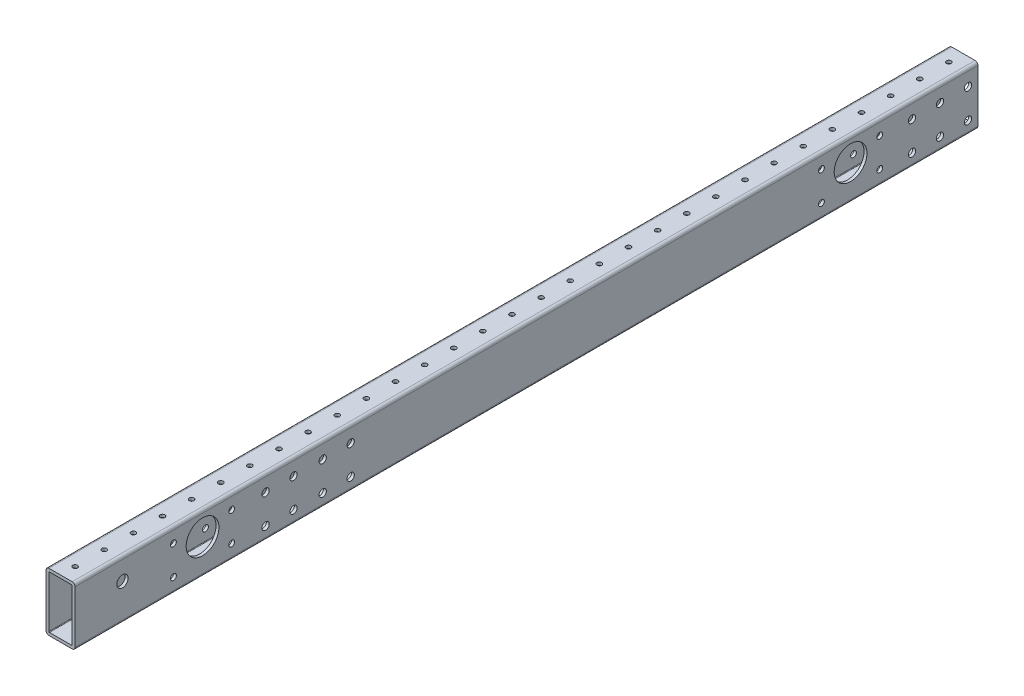
from build123d import *

# Parameters (mm, degrees)
SKETCH1_W                 = 787.4
SKETCH1_H                 = 50.8
BOSS_EXTRUDE1_DEPTH       = 25.4
SKETCH2_W                 = 20.32
SKETCH2_H                 = 45.72
CUT_EXTRUDE1_DEPTH        = 788.4
F_6_CLEARANCE_HOLE1_D     = 4.1402
F_6_CLEARANCE_HOLE1_DEPTH = 50.8
F_6_CLEARANCE_HOLE2_D     = 4.1402
F_6_CLEARANCE_HOLE2_DEPTH = 50.8
FILLET1_R                 = 0.5
FILLET2_R                 = 2.54
SKETCH7_R                 = 14.3002
CUT_EXTRUDE2_DEPTH        = 1
CUT_EXTRUDE2_DEPTH_BACK   = 26.4
SKETCH8_R                 = 3.1877
CUT_EXTRUDE3_DEPTH        = 13.7
CUT_EXTRUDE3_DEPTH_BACK   = 13.7
SKETCH10_R                = 2.5527
CUT_EXTRUDE5_DEPTH        = 13.7
CUT_EXTRUDE5_DEPTH_BACK   = 13.7
SKETCH12_R                = 4.953
CUT_EXTRUDE6_DEPTH        = 26.4


with BuildPart() as part:
    # Sketch1 → Boss-Extrude1 (new body)
    with BuildSketch(Plane(origin=(12.7, 0, 0), x_dir=(0, 0, -1), z_dir=(1, 0, 0))):
        Rectangle(SKETCH1_W, SKETCH1_H)
    extrude(amount=-BOSS_EXTRUDE1_DEPTH)

    # Sketch2 → Cut-Extrude1 (cut, through all)
    with BuildSketch(Plane(origin=(0, 0, -393.7), x_dir=(-1, 0, 0), z_dir=(0, 0, -1))):
        Rectangle(SKETCH2_W, SKETCH2_H)
    extrude(amount=-CUT_EXTRUDE1_DEPTH, mode=Mode.SUBTRACT)

    # #6 Clearance Hole1
    with Locations(Plane(origin=(0, -25.4, 0), x_dir=(-1, 0, 0), z_dir=(0, -1, 0))):
        with Locations((0, 711.2), (0, 736.6), (0, 685.8), (0, 660.4), (0, 635), (0, 609.6), (0, 584.2), (0, 558.8), (0, 533.4), (0, 508), (0, 482.6), (0, 457.2), (0, 431.8), (0, 406.4), (0, 381), (0, 355.6), (0, 330.2), (0, 304.8), (0, 279.4), (0, 254), (0, 228.6), (0, 203.2), (0, 177.8), (0, 152.4), (0, 127), (0, 101.6), (0, 76.2), (0, 50.8), (0, 25.4), (0, 0), (0, -25.4), (0, -50.8), (0, -76.2), (0, -101.6), (0, -127), (0, -152.4), (0, -177.8), (0, -203.2), (0, -228.6), (0, -254), (0, -279.4), (0, -304.8), (0, -330.2), (0, -355.6), (0, -381), (0, -406.4), (0, -431.8), (0, -457.2), (0, -482.6), (0, -508), (0, -533.4), (0, -558.8), (0, -584.2), (0, -609.6), (0, -635), (0, -660.4), (0, -685.8), (0, -711.2), (0, -736.6)):
            Hole(F_6_CLEARANCE_HOLE1_D / 2, depth=F_6_CLEARANCE_HOLE1_DEPTH)

    # #6 Clearance Hole2
    with Locations(Plane(origin=(0, 25.4, 0), x_dir=(1, 0, 0), z_dir=(0, 1, 0))):
        with Locations((0, 711.2), (0, 736.6), (0, 685.8), (0, 660.4), (0, 635), (0, 609.6), (0, 584.2), (0, 558.8), (0, 533.4), (0, 508), (0, 482.6), (0, 457.2), (0, 431.8), (0, 406.4), (0, 381), (0, 355.6), (0, 330.2), (0, 304.8), (0, 279.4), (0, 254), (0, 228.6), (0, 203.2), (0, 177.8), (0, 152.4), (0, 127), (0, 101.6), (0, 76.2), (0, 50.8), (0, 25.4), (0, 0), (0, -25.4), (0, -50.8), (0, -76.2), (0, -101.6), (0, -127), (0, -152.4), (0, -177.8), (0, -203.2), (0, -228.6), (0, -254), (0, -279.4), (0, -304.8), (0, -330.2), (0, -355.6), (0, -381), (0, -406.4), (0, -431.8), (0, -457.2), (0, -482.6), (0, -508), (0, -533.4), (0, -558.8), (0, -584.2), (0, -609.6), (0, -635), (0, -660.4), (0, -685.8), (0, -711.2), (0, -736.6)):
            Hole(F_6_CLEARANCE_HOLE2_D / 2, depth=F_6_CLEARANCE_HOLE2_DEPTH)

    # Fillet1
    fillet1_edges = [part.edges().sort_by_distance(p)[0] for p in [
        (-10.16, -22.86, 0),
        (10.16, -22.86, 0),
        (10.16, 22.86, 0),
        (-10.16, 22.86, 0),
    ]]
    fillet(fillet1_edges, radius=FILLET1_R)

    # Fillet2
    fillet2_edges = [part.edges().sort_by_distance(p)[0] for p in [
        (-12.7, 25.4, 0),
        (-12.7, -25.4, 0),
        (12.7, 25.4, 0),
        (12.7, -25.4, 0),
    ]]
    fillet(fillet2_edges, radius=FILLET2_R)

    # Sketch7 → Cut-Extrude2 (cut, two sides)
    with BuildSketch(Plane(origin=(12.7, 0, 0), x_dir=(0, 0, -1), z_dir=(1, 0, 0))) as cut_extrude2_sk:
        with Locations((282.575, 5.08)):
            Circle(SKETCH7_R)
        with Locations((-282.575, 5.08)):
            Circle(SKETCH7_R)
    extrude(amount=CUT_EXTRUDE2_DEPTH, mode=Mode.SUBTRACT)
    extrude(cut_extrude2_sk.sketch, amount=-CUT_EXTRUDE2_DEPTH_BACK, mode=Mode.SUBTRACT)

    # Sketch8 → Cut-Extrude3 (cut, two sides)
    with BuildSketch(Plane(origin=(0, 0, 0), x_dir=(0, 0, -1), z_dir=(1, 0, 0))) as cut_extrude3_sk:
        with Locations((-153.38806, 11.1125)):
            Circle(SKETCH8_R)
        with Locations((-153.38806, -14.2875)):
            Circle(SKETCH8_R)
        with Locations((-227.6094, 11.1125)):
            Circle(SKETCH8_R)
        with Locations((-227.6094, -14.2875)):
            Circle(SKETCH8_R)
        with Locations((336.14106, 11.1125)):
            Circle(SKETCH8_R)
        with Locations((336.14106, -14.2875)):
            Circle(SKETCH8_R)
        with Locations((384.9624, 11.1125)):
            Circle(SKETCH8_R)
        with Locations((384.9624, -14.2875)):
            Circle(SKETCH8_R)
        with Locations((-203.2, 11.1125)):
            Circle(SKETCH8_R)
        with Locations((-203.2, -14.2875)):
            Circle(SKETCH8_R)
        with Locations((-177.8, 11.1125)):
            Circle(SKETCH8_R)
        with Locations((-177.8, -14.2875)):
            Circle(SKETCH8_R)
        with Locations((360.553, 11.1125)):
            Circle(SKETCH8_R)
        with Locations((360.553, -14.2875)):
            Circle(SKETCH8_R)
    extrude(amount=CUT_EXTRUDE3_DEPTH, mode=Mode.SUBTRACT)
    extrude(cut_extrude3_sk.sketch, amount=-CUT_EXTRUDE3_DEPTH_BACK, mode=Mode.SUBTRACT)

    # Sketch10 → Cut-Extrude5 (cut, two sides)
    with BuildSketch(Plane(origin=(0, 0, 0), x_dir=(0, 0, -1), z_dir=(1, 0, 0))) as cut_extrude5_sk:
        with Locations((307.975, 12.7)):
            Circle(SKETCH10_R)
        with Locations((307.975, -12.7)):
            Circle(SKETCH10_R)
        with Locations((257.175, 12.7)):
            Circle(SKETCH10_R)
        with Locations((257.175, -12.7)):
            Circle(SKETCH10_R)
        with Locations((-257.175, -12.7)):
            Circle(SKETCH10_R)
        with Locations((-307.975, -12.7)):
            Circle(SKETCH10_R)
        with Locations((-257.175, 12.7)):
            Circle(SKETCH10_R)
        with Locations((-307.975, 12.7)):
            Circle(SKETCH10_R)
    extrude(amount=CUT_EXTRUDE5_DEPTH, mode=Mode.SUBTRACT)
    extrude(cut_extrude5_sk.sketch, amount=-CUT_EXTRUDE5_DEPTH_BACK, mode=Mode.SUBTRACT)

    # Sketch12 → Cut-Extrude6 (cut, through all)
    with BuildSketch(Plane.ZY.offset(12.7)):
        with Locations((352.425, 6.35)):
            Circle(SKETCH12_R)
    extrude(amount=-CUT_EXTRUDE6_DEPTH, mode=Mode.SUBTRACT)


solid = part.part
